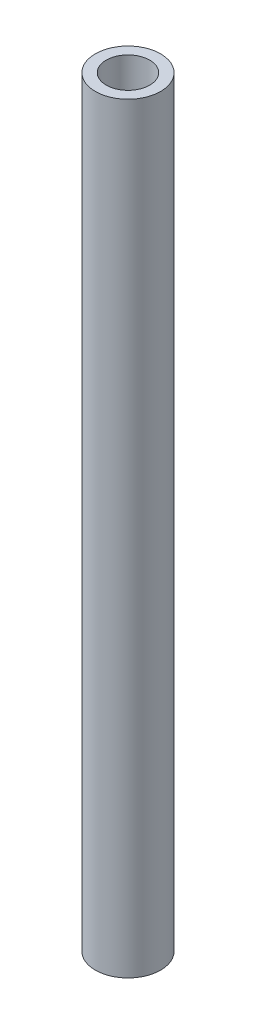
from build123d import *

# Parameters (mm, degrees)
SKETCH_1_R      = 3
SKETCH_1_R_2    = 2
EXTRUDE_1_DEPTH = 70


with BuildPart() as part:
    # 스케치1 → 보스-돌출1 (new body)
    with BuildSketch(Plane(origin=(0, 0, 0), x_dir=(1, 0, 0), z_dir=(0, 1, 0))):
        Circle(SKETCH_1_R)
        Circle(SKETCH_1_R_2, mode=Mode.SUBTRACT)
    extrude(amount=EXTRUDE_1_DEPTH)


solid = part.part
